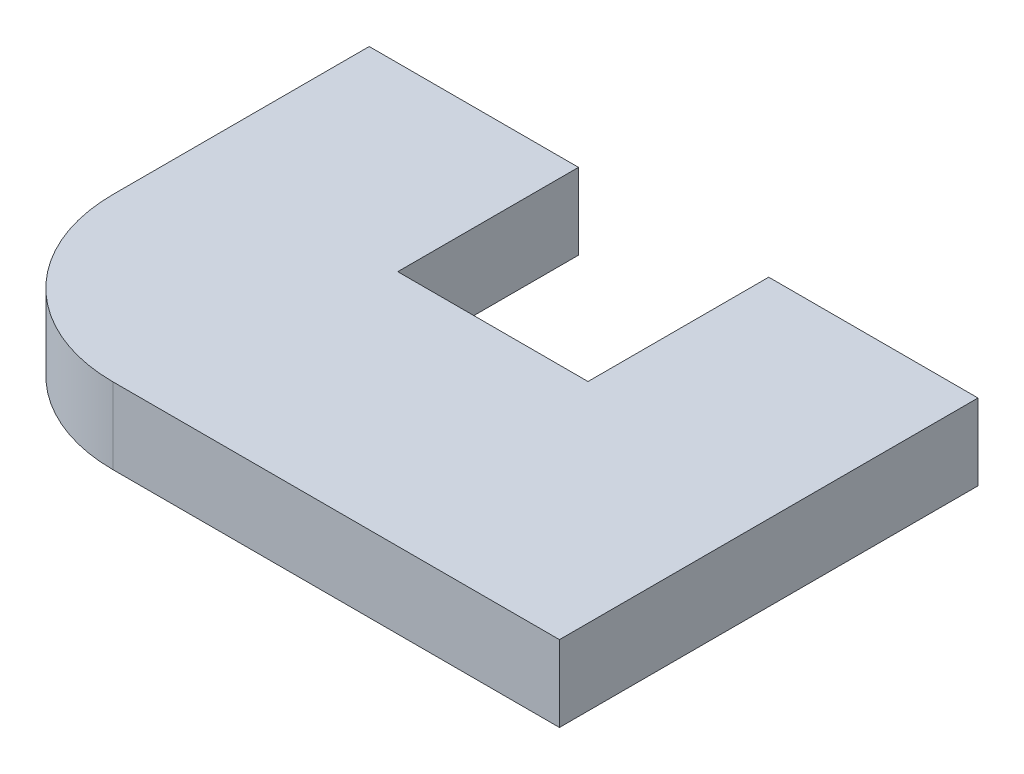
from build123d import *

# Parameters (mm, degrees)
SKETCH1_W           = 100
SKETCH1_H           = 125
BOSS_EXTRUDE1_DEPTH = 40


with BuildPart() as part:
    # Sketch1 → Boss-Extrude1 (new body)
    with BuildSketch(Plane(origin=(0, 0, 0), x_dir=(1, 0, 0), z_dir=(0, 1, 0))):
        with BuildLine():
            ThreePointArc((-55, -24.644660941), (-30, -85), (30.355339059, -110))
            Line((30.355339059, -110), (55, -110))
            Line((55, -110), (55, 15))
            Line((55, 15), (55, 110))
            Line((55, 110), (-55, 110))
            Line((-55, 110), (-55, -24.644660941))
        make_face()
        with Locations((105, -47.5)):
            Rectangle(SKETCH1_W, SKETCH1_H)
        Polygon((155, 15), (155, -110), (265, -110), (265, 110), (155, 110), align=None)
    extrude(amount=BOSS_EXTRUDE1_DEPTH)


solid = part.part
